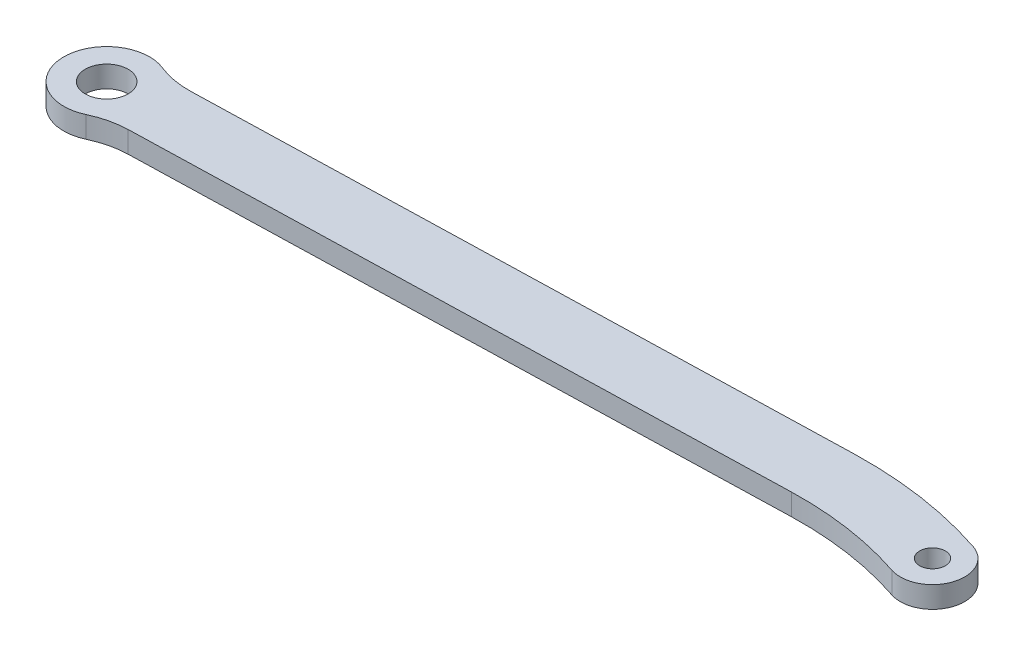
from build123d import *

# Parameters (mm, degrees)
SKETCH1_R           = 3.175
SKETCH1_R_2         = 1.905
BOSS_EXTRUDE1_DEPTH = 3.175
FILLET1_R           = 12.7


with BuildPart() as part:
    # Sketch1 → Boss-Extrude1 (new body)
    with BuildSketch(Plane(origin=(0, 0, 0), x_dir=(1, 0, 0), z_dir=(0, 1, 0))):
        with BuildLine():
            ThreePointArc((-57.050749937, 4.875846131), (-67.466363723, -0.174069026), (-56.789646398, -4.645574453))
            Line((-56.789646398, -4.645574453), (42.161094502, -1.93207299))
            ThreePointArc((42.161094502, -1.93207299), (51.000262943, -2.46173496), (59.613169718, -4.518255666))
            ThreePointArc((59.613169718, -4.518255666), (65.637005666, -1.505580282), (62.624330282, 4.518255666))
            ThreePointArc((62.624330282, 4.518255666), (52.396503486, 6.960374005), (41.899990962, 7.589347594))
            Line((41.899990962, 7.589347594), (-57.050749937, 4.875846131))
        make_face()
        with Locations((-61.11875, 0)):
            Circle(SKETCH1_R, mode=Mode.SUBTRACT)
        with Locations((61.11875, 0)):
            Circle(SKETCH1_R_2, mode=Mode.SUBTRACT)
    extrude(amount=BOSS_EXTRUDE1_DEPTH)

    # Fillet1
    fillet1_edges = [part.edges().sort_by_distance(p)[0] for p in [
        (-56.789646398, 1.5875, 4.645574453),
        (-57.050749937, 1.5875, -4.875846131),
    ]]
    fillet(fillet1_edges, radius=FILLET1_R)


solid = part.part
